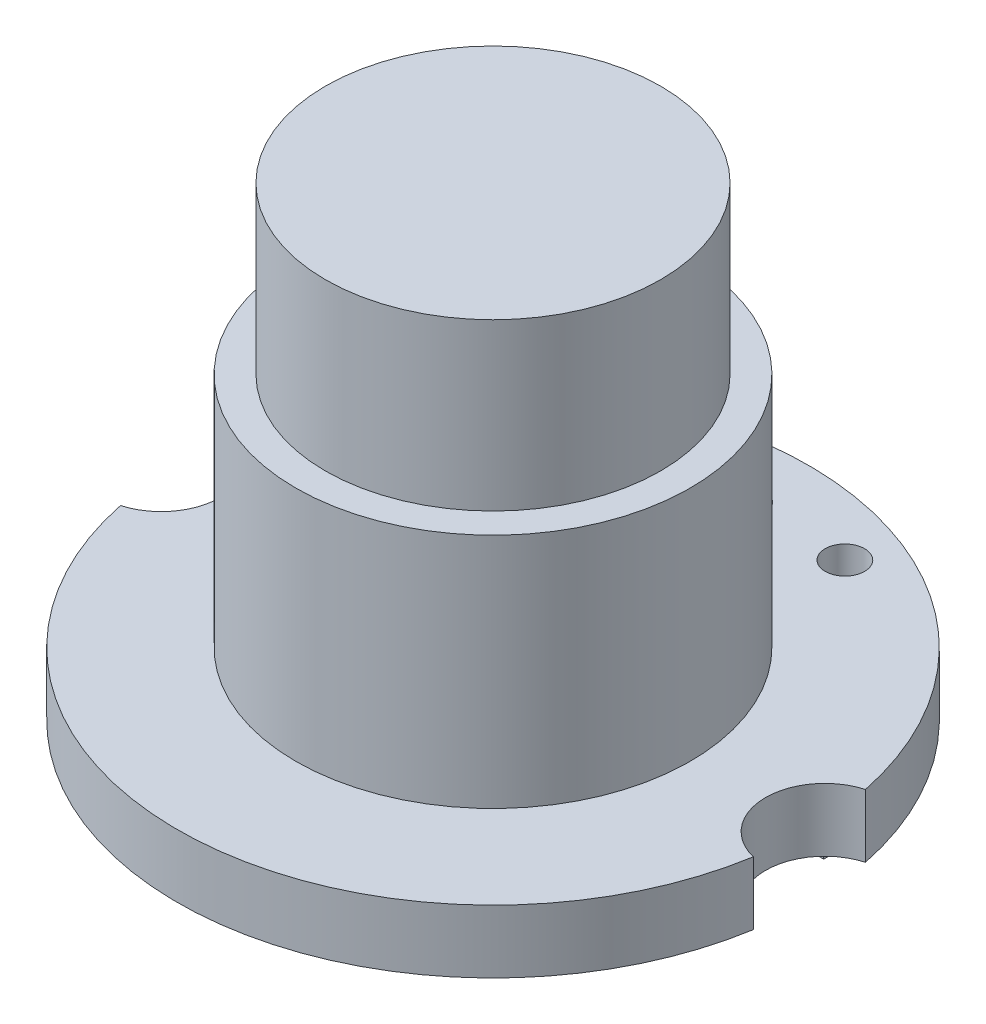
from build123d import *

# Parameters (mm, degrees)
EXTRUDE_1_DEPTH     = 1.6
SKETCH_2_R          = 5
EXTRUDE_2_DEPTH     = 6
EXTRUDE_START       = -6
SKETCH_3_R          = 4.25
EXTRUDE_3_DEPTH     = 10.2
SKETCH_4_R          = 0.5
CUT_EXTRUDE_1_DEPTH = 2.6
EXTRUDE_START_2     = -1.6
SKETCH_5_W          = 0.976311431
SKETCH_5_H          = 2.037519509
EXTRUDE_4_DEPTH     = 3.3


with BuildPart() as part:
    # 草图1 → 凸台-拉伸1 (new body)
    with BuildSketch(Plane(origin=(0, 0, 0), x_dir=(1, 0, 0), z_dir=(0, 1, 0))):
        with BuildLine():
            ThreePointArc((7.894379623, -1.295673712), (6.748699348, 0.13250325), (7.837436926, 1.604550536))
            ThreePointArc((7.837436926, 1.604550536), (-0.157040889, 7.998458486), (-7.894379623, 1.295673712))
            ThreePointArc((-7.894379623, 1.295673712), (-6.748699348, -0.13250325), (-7.837436926, -1.604550536))
            ThreePointArc((-7.837436926, -1.604550536), (0.157040889, -7.998458486), (7.894379623, -1.295673712))
        make_face()
    extrude(amount=EXTRUDE_1_DEPTH)

    # 草图2 → 凸台-拉伸2 (add)
    with BuildSketch(Plane(origin=(0, 1.6, 0), x_dir=(1, 0, 0), z_dir=(0, 1, 0))):
        Circle(SKETCH_2_R)
    extrude(amount=EXTRUDE_2_DEPTH)

    # 草图3 → 凸台-拉伸3 (add)
    with BuildSketch(Plane(origin=(0, 7.6, 0), x_dir=(1, 0, 0), z_dir=(0, 1, 0)).offset(EXTRUDE_START)):
        Circle(SKETCH_3_R)
    extrude(amount=EXTRUDE_3_DEPTH)

    # 草图4 → 切除-拉伸1 (cut, through all)
    with BuildSketch(Plane(origin=(0, 1.6, 0), x_dir=(1, 0, 0), z_dir=(0, 1, 0))):
        with Locations((-2.54, 6.380087041)):
            Circle(SKETCH_4_R)
        with Locations((0, 6.380087041)):
            Circle(SKETCH_4_R)
        with Locations((2.54, 6.380087041)):
            Circle(SKETCH_4_R)
    extrude(amount=-CUT_EXTRUDE_1_DEPTH, mode=Mode.SUBTRACT)

    # 草图5 → 凸台-拉伸4 (add)
    with BuildSketch(Plane.XZ.offset(EXTRUDE_START_2)):
        with Locations((5.05135045, -3.862797403)):
            Rectangle(SKETCH_5_W, SKETCH_5_H)
    extrude(amount=EXTRUDE_4_DEPTH)


solid = part.part
